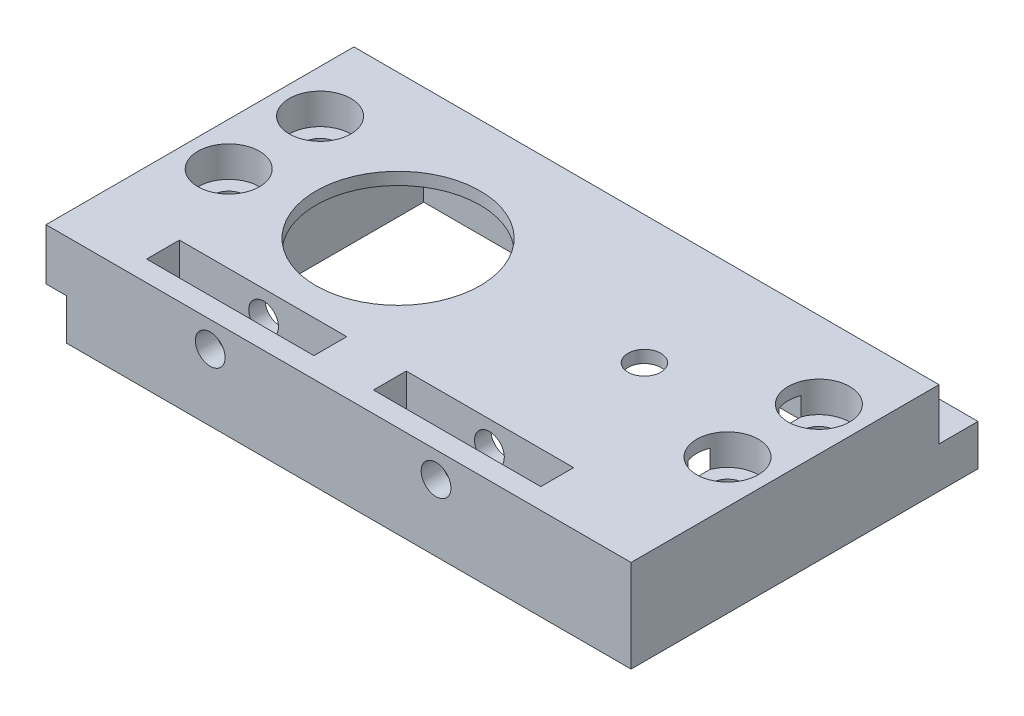
from build123d import *

# Parameters (mm, degrees)
SKETCH1_W                = 50
SKETCH1_H                = 25
SKETCH1_R                = 4.5
SKETCH1_R_2              = 1.3
BOSS_EXTRUDE2_DEPTH      = 2.5
SKETCH5_W                = 50
SKETCH5_H                = 12
BOSS_EXTRUDE3_DEPTH      = 1.5
SKETCH6_W                = 50
SKETCH6_H                = 26.5
BOSS_EXTRUDE4_DEPTH      = 1.5
SKETCH7_R                = 1.3
CUT_EXTRUDE3_DEPTH       = 23
SKETCH8_R                = 1.6
BOSS_EXTRUDE5_DEPTH      = 4
SKETCH8_3_R              = 8
CUT_EXTRUDE4_DEPTH       = 5
SKETCH9_W                = 24.55
SKETCH9_H                = 21.7
CUT_EXTRUDE5_DEPTH       = 3.8
BOSS_EXTRUDE6_DEPTH      = 22.95
BOSS_EXTRUDE7_DEPTH      = 2
SKETCH8_4_R              = 1.6
CUT_EXTRUDE6_DEPTH       = 5
SKETCH12_W               = 7
SKETCH12_H               = 21
BOSS_EXTRUDE8_DEPTH      = 7.8
SKETCH13_W               = 0.7
SKETCH13_H               = 9
CUT_EXTRUDE7_DEPTH       = 50.95
CUT_EXTRUDE7_DEPTH_BACK  = 26
SKETCH14_W               = 26.5
SKETCH14_H               = 8.5
CUT_EXTRUDE8_DEPTH       = 50.95
CUT_EXTRUDE8_DEPTH_BACK  = 26
SKETCH15_R               = 3
CUT_EXTRUDE9_DEPTH       = 1
CUT_EXTRUDE9_DEPTH_BACK  = 3
SKETCH8_5_R              = 1.6
CUT_EXTRUDE10_DEPTH      = 5
CUT_EXTRUDE10_DEPTH_BACK = 6
SKETCH16_W               = 16.3
SKETCH16_H               = 5
CUT_EXTRUDE11_DEPTH      = 3.2
SKETCH17_R               = 1.45
CUT_EXTRUDE12_DEPTH      = 13.2
SKETCH18_R               = 1.6
CUT_EXTRUDE13_DEPTH      = 3.2
SKETCH19_W               = 17.95
SKETCH19_H               = 5
CUT_EXTRUDE14_DEPTH      = 33.2
BOSS_EXTRUDE9_DEPTH      = 2
SKETCH21_W               = 1.5
SKETCH21_H               = 5
BOSS_EXTRUDE10_DEPTH     = 32.05
SKETCH23_W               = 0.2
SKETCH23_H               = 3.8
CUT_EXTRUDE15_DEPTH      = 42.95
SKETCH17_2_R             = 1.45
CUT_EXTRUDE16_DEPTH      = 20


with BuildPart() as part:
    # Sketch1 → Boss-Extrude2 (new body, symmetric)
    with BuildSketch(Plane(origin=(0, 0, 0), x_dir=(1, 0, 0), z_dir=(0, 1, 0))):
        Rectangle(SKETCH1_W, SKETCH1_H)
        with Locations((11.25, 0)):
            Circle(SKETCH1_R, mode=Mode.SUBTRACT)
        with Locations((-11.25, 0)):
            Circle(SKETCH1_R_2, mode=Mode.SUBTRACT)
    extrude(amount=BOSS_EXTRUDE2_DEPTH, both=True)

    # Sketch5 → Boss-Extrude3 (add, symmetric)
    with BuildSketch(Plane.XY.offset(12.5)):
        with Locations((0, 3.5)):
            Rectangle(SKETCH5_W, SKETCH5_H)
    extrude(amount=BOSS_EXTRUDE3_DEPTH, both=True)

    # Sketch6 → Boss-Extrude4 (add, symmetric)
    with BuildSketch(Plane(origin=(0, 9.5, 0), x_dir=(1, 0, 0), z_dir=(0, 1, 0))):
        with Locations((0, -0.75)):
            Rectangle(SKETCH6_W, SKETCH6_H)
    extrude(amount=BOSS_EXTRUDE4_DEPTH, both=True)

    # Sketch7 → Cut-Extrude3 (cut)
    with BuildSketch(Plane(origin=(0, 11, 0), x_dir=(1, 0, 0), z_dir=(0, 1, 0))):
        with Locations((-11.25, 0)):
            Circle(SKETCH7_R)
        with Locations((11.25, 0)):
            Circle(SKETCH7_R)
    extrude(amount=-CUT_EXTRUDE3_DEPTH, mode=Mode.SUBTRACT)

    # Sketch8 → Boss-Extrude5 (add)
    with BuildSketch(Plane.XZ.offset(2.5)):
        Polygon((47.95, 14.7), (-5.05, 14.7), (-5.05, 14), (25, 14), (25, 9.2), (42.45, 9.2), (42.45, -13.3), (0.45, -13.3), (0.45, -12.5), (-5.05, -12.5), (-5.05, -17.8), (47.95, -17.8), align=None)
        with Locations((45.75, -6.5)):
            Circle(SKETCH8_R, mode=Mode.SUBTRACT)
        with Locations((45.75, 2.4)):
            Circle(SKETCH8_R, mode=Mode.SUBTRACT)
        Polygon((25, 14), (-5.05, 14), (-5.05, -12.5), (0.45, -12.5), (0.45, 9.2), (25, 9.2), align=None)
        with Locations((-2.85, -6.5)):
            Circle(SKETCH8_R, mode=Mode.SUBTRACT)
        with Locations((-2.85, 2.4)):
            Circle(SKETCH8_R, mode=Mode.SUBTRACT)
    extrude(amount=BOSS_EXTRUDE5_DEPTH)

    # Sketch8_3 → Cut-Extrude4 (cut)
    with BuildSketch(Plane.XZ.offset(2.5)):
        with Locations((11.25, 0)):
            Circle(SKETCH8_3_R)
    extrude(amount=-CUT_EXTRUDE4_DEPTH, mode=Mode.SUBTRACT)

    # Sketch9 → Cut-Extrude5 (cut)
    with BuildSketch(Plane.XZ.offset(2.5)):
        with Locations((12.725, -1.65)):
            Rectangle(SKETCH9_W, SKETCH9_H)
    extrude(amount=-CUT_EXTRUDE5_DEPTH, mode=Mode.SUBTRACT)

    # Sketch10 → Boss-Extrude6 (add)
    with BuildSketch(Plane(origin=(25, 0, 0), x_dir=(0, 0, -1), z_dir=(1, 0, 0))):
        Polygon((-14.7, -2.5), (-14.7, 2.5), (14, 2.5), (14, -2.5), (12.3, -2.5), (12.3, 1.3), (-9.2, 1.3), (-9.2, -2.5), align=None)
    extrude(amount=BOSS_EXTRUDE6_DEPTH)

    # Sketch11 → Boss-Extrude7 (add)
    with BuildSketch(Plane(origin=(47.95, 0, 0), x_dir=(0, 0, -1), z_dir=(1, 0, 0))):
        Polygon((-14.7, 2.5), (14, 2.5), (14, -2.5), (17.8, -2.5), (17.8, -6.5), (-14.7, -6.5), align=None)
    extrude(amount=BOSS_EXTRUDE7_DEPTH)

    # Sketch8_4 → Cut-Extrude6 (cut)
    with BuildSketch(Plane.XZ.offset(2.5)):
        with Locations((45.75, -6.5)):
            Circle(SKETCH8_4_R)
        with Locations((45.75, 2.4)):
            Circle(SKETCH8_4_R)
        with Locations((-2.85, -6.5)):
            Circle(SKETCH8_4_R)
        with Locations((-2.85, 2.4)):
            Circle(SKETCH8_4_R)
    extrude(amount=-CUT_EXTRUDE6_DEPTH, mode=Mode.SUBTRACT)

    # Sketch12 → Boss-Extrude8 (add)
    with BuildSketch(Plane.XZ.offset(-1.3)):
        with Locations((46.45, -1.8)):
            Rectangle(SKETCH12_W, SKETCH12_H)
    extrude(amount=BOSS_EXTRUDE8_DEPTH)

    # Sketch13 → Cut-Extrude7 (cut, two sides)
    with BuildSketch(Plane(origin=(0, 0, 0), x_dir=(0, 0, -1), z_dir=(1, 0, 0))) as cut_extrude7_sk:
        with Locations((-14.35, -2)):
            Rectangle(SKETCH13_W, SKETCH13_H)
    extrude(amount=CUT_EXTRUDE7_DEPTH, mode=Mode.SUBTRACT)
    extrude(cut_extrude7_sk.sketch, amount=-CUT_EXTRUDE7_DEPTH_BACK, mode=Mode.SUBTRACT)

    # Sketch14 → Cut-Extrude8 (cut, two sides)
    with BuildSketch(Plane(origin=(0, 0, 0), x_dir=(0, 0, -1), z_dir=(1, 0, 0))) as cut_extrude8_sk:
        with Locations((-0.75, 6.75)):
            Rectangle(SKETCH14_W, SKETCH14_H)
    extrude(amount=CUT_EXTRUDE8_DEPTH, mode=Mode.SUBTRACT)
    extrude(cut_extrude8_sk.sketch, amount=-CUT_EXTRUDE8_DEPTH_BACK, mode=Mode.SUBTRACT)

    # Sketch15 → Cut-Extrude9 (cut, two sides)
    with BuildSketch(Plane(origin=(0, 2.5, 0), x_dir=(1, 0, 0), z_dir=(0, 1, 0))) as cut_extrude9_sk:
        with Locations((-2.85, 6.5)):
            Circle(SKETCH15_R)
        with Locations((-2.85, -2.4)):
            Circle(SKETCH15_R)
        with Locations((45.75, 6.5)):
            Circle(SKETCH15_R)
        with Locations((45.75, -2.4)):
            Circle(SKETCH15_R)
    extrude(amount=CUT_EXTRUDE9_DEPTH, mode=Mode.SUBTRACT)
    extrude(cut_extrude9_sk.sketch, amount=-CUT_EXTRUDE9_DEPTH_BACK, mode=Mode.SUBTRACT)

    # Sketch8_5 → Cut-Extrude10 (cut, two sides)
    with BuildSketch(Plane.XZ.offset(2.5)) as cut_extrude10_sk:
        with Locations((45.75, -6.5)):
            Circle(SKETCH8_5_R)
        with Locations((45.75, 2.4)):
            Circle(SKETCH8_5_R)
    extrude(amount=CUT_EXTRUDE10_DEPTH, mode=Mode.SUBTRACT)
    extrude(cut_extrude10_sk.sketch, amount=-CUT_EXTRUDE10_DEPTH_BACK, mode=Mode.SUBTRACT)

    # Sketch16 → Cut-Extrude11 (cut)
    with BuildSketch(Plane.XY.offset(14)):
        with Locations((8.9, 0)):
            Rectangle(SKETCH16_W, SKETCH16_H)
        with Locations((31, 0)):
            Rectangle(SKETCH16_W, SKETCH16_H)
    extrude(amount=-CUT_EXTRUDE11_DEPTH, mode=Mode.SUBTRACT)

    # Sketch17 → Cut-Extrude12 (cut)
    with BuildSketch(Plane.XY):
        with Locations((8.95, 0)):
            Circle(SKETCH17_R)
        with Locations((30.95, 0)):
            Circle(SKETCH17_R)
    extrude(amount=CUT_EXTRUDE12_DEPTH, mode=Mode.SUBTRACT)

    # Sketch18 → Cut-Extrude13 (cut)
    with BuildSketch(Plane(origin=(0, 2.5, 0), x_dir=(1, 0, 0), z_dir=(0, 1, 0))):
        with Locations((33.75, 1.5)):
            Circle(SKETCH18_R)
    extrude(amount=-CUT_EXTRUDE13_DEPTH, mode=Mode.SUBTRACT)

    # Sketch19 → Cut-Extrude14 (cut)
    with BuildSketch(Plane.XY.offset(14)):
        with Locations((-16.025, 0)):
            Rectangle(SKETCH19_W, SKETCH19_H)
    extrude(amount=-CUT_EXTRUDE14_DEPTH, mode=Mode.SUBTRACT)

    # Sketch20 → Boss-Extrude9 (add)
    with BuildSketch(Plane.XY.offset(14)):
        Polygon((-7.05, 2.5), (49.95, 2.5), (49.95, -6.5), (-5.05, -6.5), (-5.05, -2.5), (-7.05, -2.5), align=None)
    extrude(amount=BOSS_EXTRUDE9_DEPTH)

    # Sketch21 → Boss-Extrude10 (add)
    with BuildSketch(Plane.ZY.offset(-25)):
        with Locations((-13.25, 0)):
            Rectangle(SKETCH21_W, SKETCH21_H)
    extrude(amount=BOSS_EXTRUDE10_DEPTH)

    # Sketch23 → Cut-Extrude15 (cut)
    with BuildSketch(Plane(origin=(0, 0, 0), x_dir=(0, 0, -1), z_dir=(1, 0, 0))):
        with Locations((12.4, -0.6)):
            Rectangle(SKETCH23_W, SKETCH23_H)
    extrude(amount=CUT_EXTRUDE15_DEPTH, mode=Mode.SUBTRACT)

    # Sketch17_2 → Cut-Extrude16 (cut)
    with BuildSketch(Plane.XY):
        with Locations((8.95, 0)):
            Circle(SKETCH17_2_R)
        with Locations((30.95, 0)):
            Circle(SKETCH17_2_R)
    extrude(amount=CUT_EXTRUDE16_DEPTH, mode=Mode.SUBTRACT)


solid = part.part
